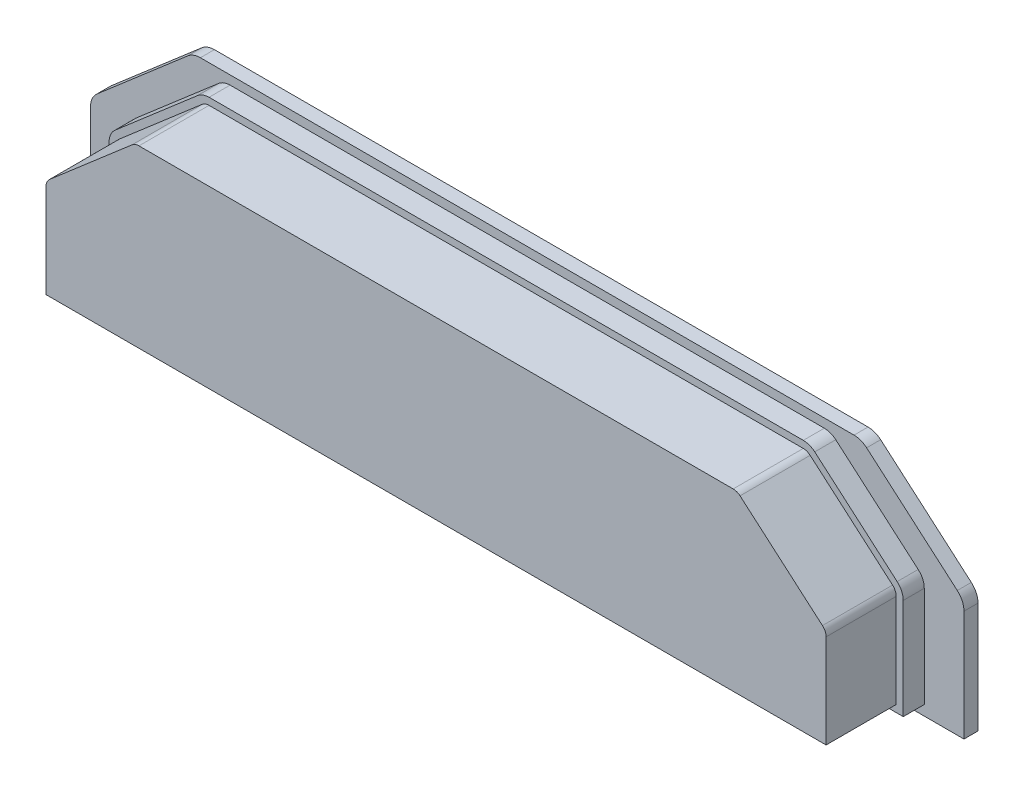
from build123d import *

# Parameters (mm, degrees)
BOSS_EXTRUDE1_DEPTH = 3
BOSS_EXTRUDE4_DEPTH = 10
BOSS_EXTRUDE5_DEPTH = 2


with BuildPart() as part:
    # Sketch2 → Boss-Extrude1 (new body)
    with BuildSketch(Plane(origin=(0, 3, 0), x_dir=(1, 0, 0), z_dir=(0, 0, 1))):
        with BuildLine():
            Line((-56.625, -30), (56.625, -30))
            Line((56.625, -30), (56.625, -15.644630074))
            ThreePointArc((56.625, -15.644630074), (56.398076263, -14.603897494), (55.758500558, -13.752098455))
            Line((55.758500558, -13.752098455), (44.005193779, -3.607468381))
            ThreePointArc((44.005193779, -3.607468381), (43.243091796, -3.156783296), (42.371693222, -3))
            Line((42.371693222, -3), (-42.371693222, -3))
            ThreePointArc((-42.371693222, -3), (-43.243091796, -3.156783296), (-44.005193779, -3.607468381))
            Line((-44.005193779, -3.607468381), (-55.758500558, -13.752098455))
            ThreePointArc((-55.758500558, -13.752098455), (-56.398076263, -14.603897494), (-56.625, -15.644630074))
            Line((-56.625, -15.644630074), (-56.625, -30))
        make_face()
    extrude(amount=BOSS_EXTRUDE1_DEPTH)

    # Sketch5 → Boss-Extrude4 (add)
    with BuildSketch(Plane.XY.offset(3)):
        with BuildLine():
            Line((55.625, -26), (55.625, -12.644630074))
            ThreePointArc((55.625, -12.644630074), (55.488845758, -12.020190526), (55.105100335, -11.509111102))
            Line((55.105100335, -11.509111102), (43.351793556, -1.364481029))
            ThreePointArc((43.351793556, -1.364481029), (42.894532367, -1.094069977), (42.371693222, -1))
            Line((42.371693222, -1), (-42.371693222, -1))
            ThreePointArc((-42.371693222, -1), (-42.894532367, -1.094069977), (-43.351793556, -1.364481029))
            Line((-43.351793556, -1.364481029), (-55.105100335, -11.509111102))
            ThreePointArc((-55.105100335, -11.509111102), (-55.488845758, -12.020190526), (-55.625, -12.644630074))
            Line((-55.625, -12.644630074), (-55.625, -26))
            Line((-55.625, -26), (55.625, -26))
        make_face()
    extrude(amount=BOSS_EXTRUDE4_DEPTH)

    # Sketch6 → Boss-Extrude5 (add)
    with BuildSketch(Plane(origin=(0, 0, 0), x_dir=(-1, 0, 0), z_dir=(0, 0, -1))):
        with BuildLine():
            Line((-62.2875, -12.644630074), (-62.2875, -28.435536993))
            Line((-62.2875, -28.435536993), (62.2875, -28.435536993))
            Line((62.2875, -28.435536993), (62.2875, -12.644630074))
            ThreePointArc((62.2875, -12.644630074), (62.037883889, -11.499824236), (61.334350613, -10.562845293))
            Line((61.334350613, -10.562845293), (48.405713157, 0.596247788))
            ThreePointArc((48.405713157, 0.596247788), (47.567400976, 1.092001382), (46.608862544, 1.264463007))
            Line((46.608862544, 1.264463007), (-46.608862544, 1.264463007))
            ThreePointArc((-46.608862544, 1.264463007), (-47.567400976, 1.092001382), (-48.405713157, 0.596247788))
            Line((-48.405713157, 0.596247788), (-61.334350613, -10.562845293))
            ThreePointArc((-61.334350613, -10.562845293), (-62.037883889, -11.499824236), (-62.2875, -12.644630074))
        make_face()
    extrude(amount=BOSS_EXTRUDE5_DEPTH)


solid = part.part
